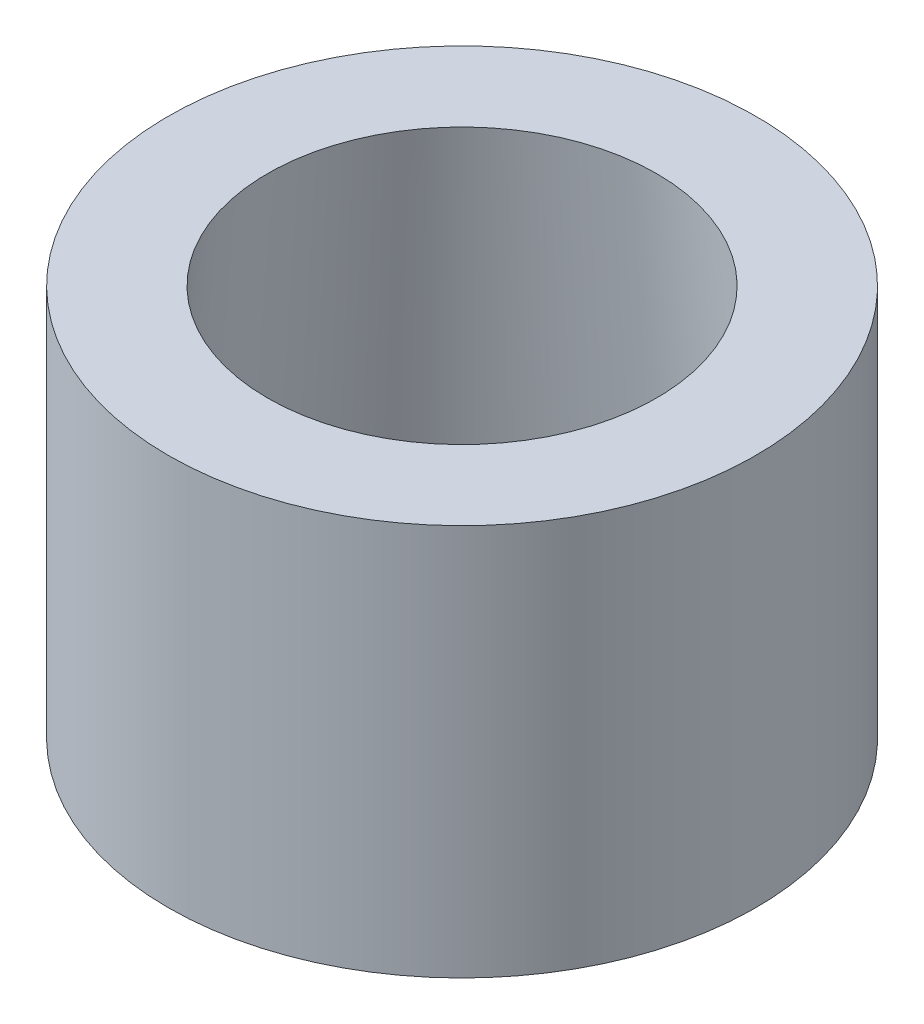
from build123d import *

# Parameters (mm, degrees)
SKETCH1_R           = 19.05
BOSS_EXTRUDE1_DEPTH = 25.4
SKETCH3_R           = 12.6111
SKETCH2_R           = 14.732


with BuildPart() as part:
    # Sketch1 → Boss-Extrude1 (new body)
    with BuildSketch(Plane(origin=(0, 0, 0), x_dir=(1, 0, 0), z_dir=(0, 1, 0))):
        Circle(SKETCH1_R)
    extrude(amount=BOSS_EXTRUDE1_DEPTH)

    # Sketch3 → Cut-Loft2 section 0
    with BuildSketch(Plane(origin=(0, 25.4, 0), x_dir=(1, 0, 0), z_dir=(0, 1, 0))):
        Circle(SKETCH3_R)
    # Sketch2 → Cut-Loft2 section 1
    with BuildSketch(Plane.XZ):
        Circle(SKETCH2_R)
    loft(mode=Mode.SUBTRACT)


solid = part.part
